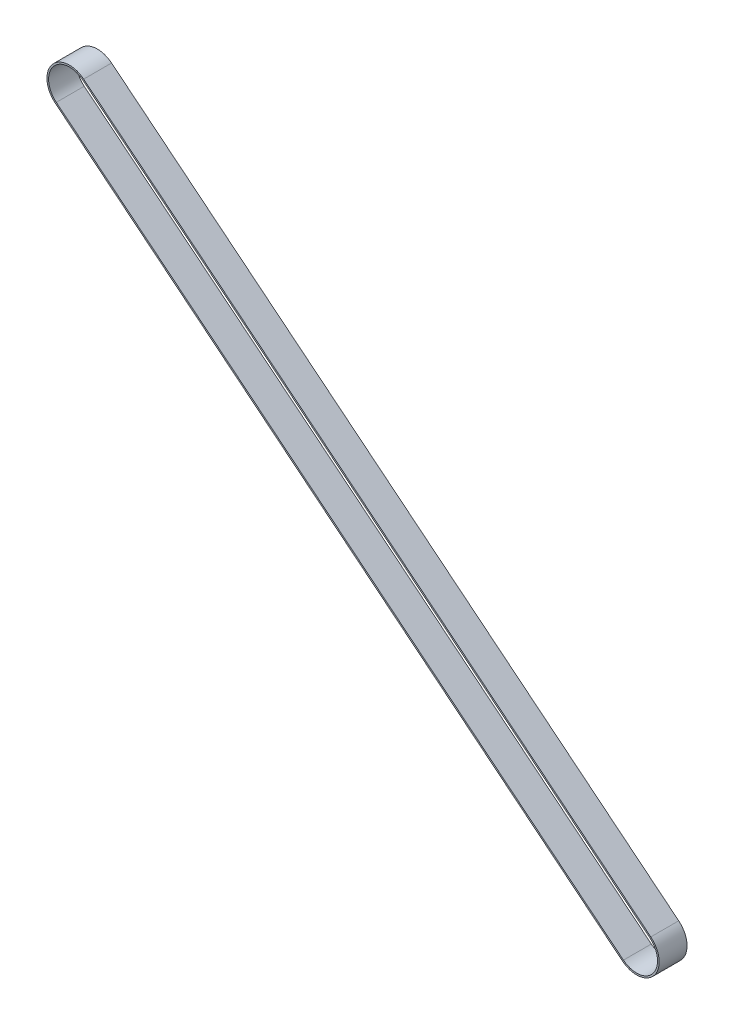
from build123d import *

# Parameters (mm, degrees)
EXTRUDE_1_DEPTH = 3


with BuildPart() as part:
    # 草图2 → 拉伸-薄壁1 (new, symmetric)
    with BuildSketch(Plane.XY):
        with BuildLine():
            Line((118.947677661, -102.569061997), (-3.052322339, -3.769061997))
            ThreePointArc((-3.052322339, -3.769061997), (-3.769061997, 3.052322339), (3.052322339, 3.769061997))
            Line((3.052322339, 3.769061997), (125.052322339, -95.030938003))
            ThreePointArc((125.052322339, -95.030938003), (125.769061997, -101.852322339), (118.947677661, -102.569061997))
        make_face()
        with BuildLine():
            Line((119.167948345, -102.297067833), (-2.832051655, -3.497067833))
            ThreePointArc((-2.832051655, -3.497067833), (-3.497067833, 2.832051655), (2.832051655, 3.497067833))
            Line((2.832051655, 3.497067833), (124.832051655, -95.302932167))
            ThreePointArc((124.832051655, -95.302932167), (125.497067833, -101.632051655), (119.167948345, -102.297067833))
        make_face(mode=Mode.SUBTRACT)
    extrude(amount=EXTRUDE_1_DEPTH, both=True)


solid = part.part
